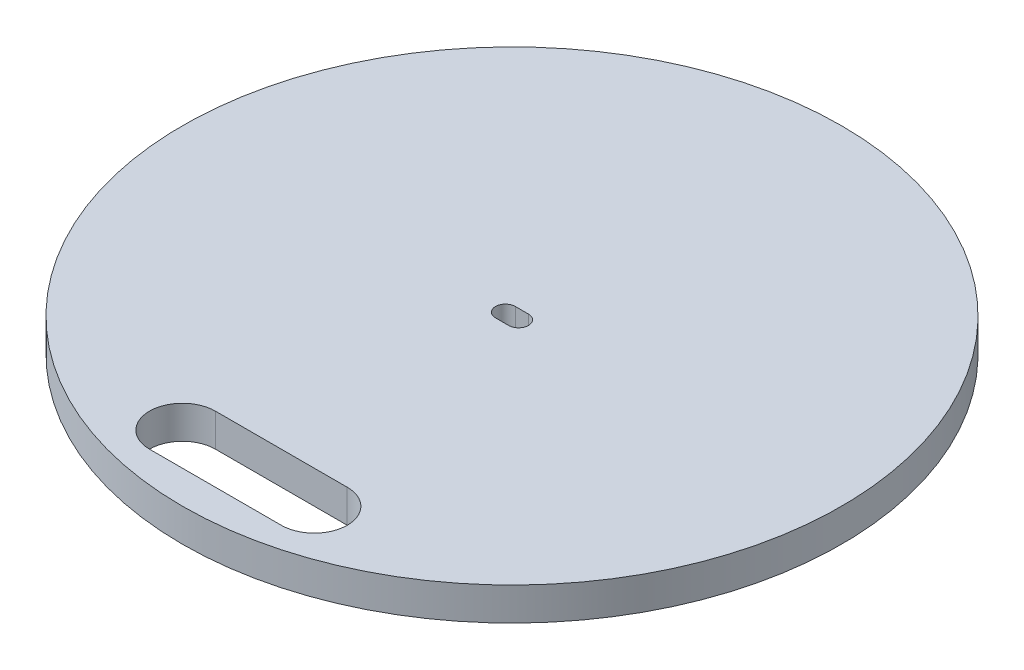
from build123d import *

# Parameters (mm, degrees)
SKETCH1_R           = 50
BOSS_EXTRUDE1_DEPTH = 5
CUT_EXTRUDE1_DEPTH  = 6
CUT_EXTRUDE2_DEPTH  = 6


with BuildPart() as part:
    # Sketch1 → Boss-Extrude1 (new body)
    with BuildSketch(Plane(origin=(0, 0, 0), x_dir=(1, 0, 0), z_dir=(0, 1, 0))):
        Circle(SKETCH1_R)
    extrude(amount=BOSS_EXTRUDE1_DEPTH)

    # Sketch3 → Cut-Extrude1 (cut, through all)
    with BuildSketch(Plane(origin=(0, 5, 0), x_dir=(1, 0, 0), z_dir=(0, 1, 0))):
        with BuildLine():
            Line((-1, 1.5), (1, 1.5))
            ThreePointArc((1, 1.5), (2.5, 0), (1, -1.5))
            Line((1, -1.5), (-1, -1.5))
            ThreePointArc((-1, -1.5), (-2.5, 0), (-1, 1.5))
        make_face()
    extrude(amount=-CUT_EXTRUDE1_DEPTH, mode=Mode.SUBTRACT)

    # Sketch5 → Cut-Extrude2 (cut, through all)
    with BuildSketch(Plane(origin=(0, 5, 0), x_dir=(1, 0, 0), z_dir=(0, 1, 0))):
        with BuildLine():
            Line((-10, -35), (10, -35))
            ThreePointArc((10, -35), (15, -40), (10, -45))
            Line((10, -45), (-10, -45))
            ThreePointArc((-10, -45), (-15, -40), (-10, -35))
        make_face()
    extrude(amount=-CUT_EXTRUDE2_DEPTH, mode=Mode.SUBTRACT)


solid = part.part
